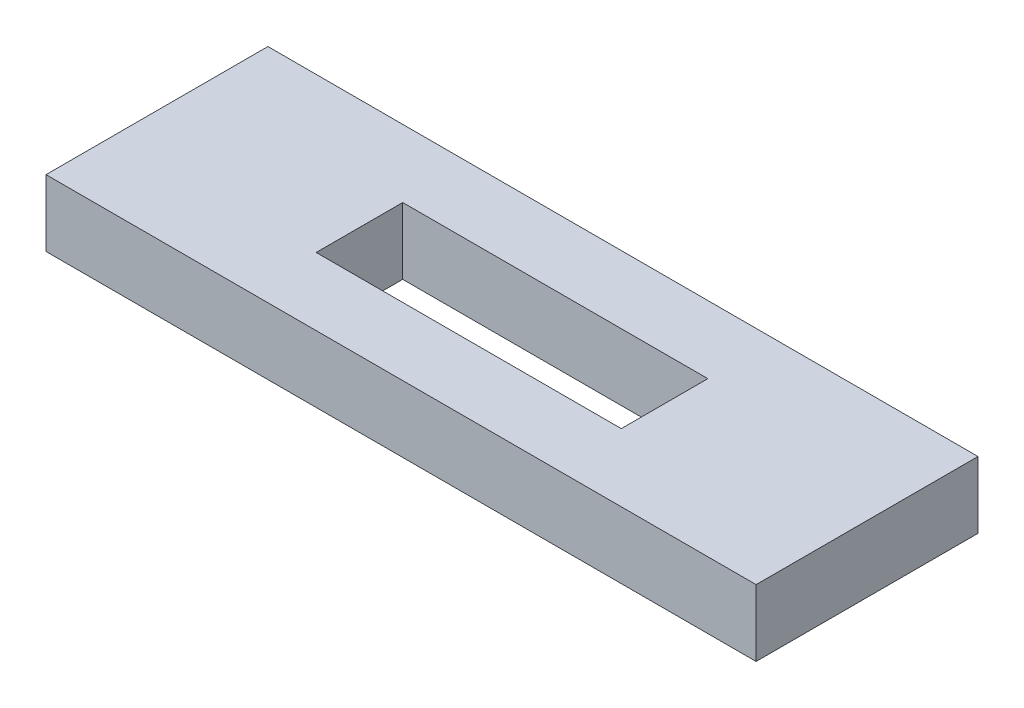
from build123d import *

# Parameters (mm, degrees)
SKETCH_1_W          = 32
SKETCH_1_H          = 10
EXTRUDE_1_DEPTH     = 3
SKETCH_2_W          = 13.75
SKETCH_2_H          = 3.9
CUT_EXTRUDE_1_DEPTH = 4


with BuildPart() as part:
    # 草圖1 → 填料-伸長1 (new body)
    with BuildSketch(Plane(origin=(0, 0, 0), x_dir=(1, 0, 0), z_dir=(0, 1, 0))):
        Rectangle(SKETCH_1_W, SKETCH_1_H)
    extrude(amount=EXTRUDE_1_DEPTH)

    # 草圖2 → 除料-伸長1 (cut, through all)
    with BuildSketch(Plane(origin=(0, 3, 0), x_dir=(1, 0, 0), z_dir=(0, 1, 0))):
        Rectangle(SKETCH_2_W, SKETCH_2_H)
    extrude(amount=-CUT_EXTRUDE_1_DEPTH, mode=Mode.SUBTRACT)


solid = part.part
